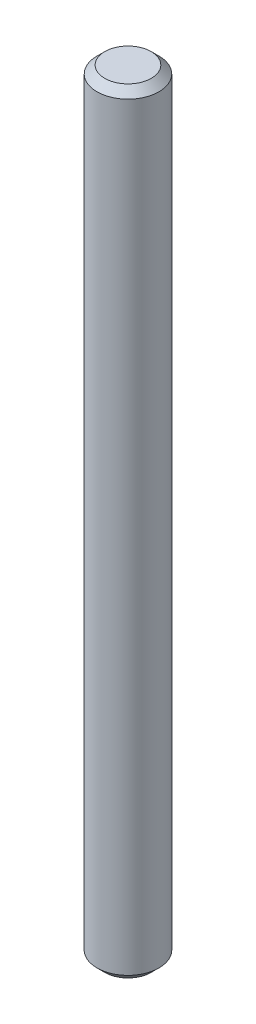
from build123d import *

# Parameters (mm, degrees)
SKETCH1_R           = 2
BOSS_EXTRUDE1_DEPTH = 50
CHAMFER1_SIZE       = 0.5


with BuildPart() as part:
    # Sketch1 → Boss-Extrude1 (new body)
    with BuildSketch(Plane(origin=(0, 0, 0), x_dir=(1, 0, 0), z_dir=(0, 1, 0))):
        Circle(SKETCH1_R)
    extrude(amount=BOSS_EXTRUDE1_DEPTH)

    # Chamfer1
    chamfer1_edges = [part.edges().sort_by_distance(p)[0] for p in [
        (-2, 0, 0),
        (-2, 50, 0),
    ]]
    chamfer(chamfer1_edges, length=CHAMFER1_SIZE)


solid = part.part
